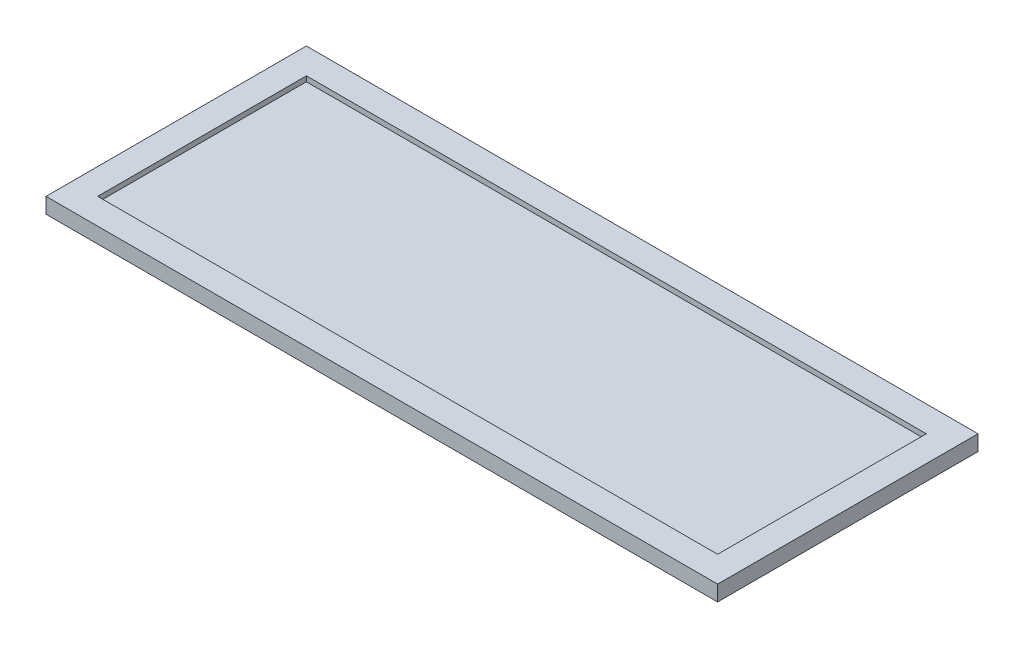
from build123d import *

# Parameters (mm, degrees)
SKETCH_1_W      = 650
SKETCH_1_H      = 252
SKETCH_1_W_2    = 600
SKETCH_1_H_2    = 202
EXTRUDE_1_DEPTH = 7.5
SKETCH_2_W      = 600
SKETCH_2_H      = 202
EXTRUDE_2_DEPTH = 2.5


with BuildPart() as part:
    # 草图1 → 凸台-拉伸1 (new body, symmetric)
    with BuildSketch(Plane(origin=(0, 0, 0), x_dir=(1, 0, 0), z_dir=(0, 1, 0))):
        Rectangle(SKETCH_1_W, SKETCH_1_H)
        Rectangle(SKETCH_1_W_2, SKETCH_1_H_2, mode=Mode.SUBTRACT)
    extrude(amount=EXTRUDE_1_DEPTH, both=True)

    # 草图2 → 凸台-拉伸2 (add, symmetric)
    with BuildSketch(Plane(origin=(0, 0, 0), x_dir=(1, 0, 0), z_dir=(0, 1, 0))):
        Rectangle(SKETCH_2_W, SKETCH_2_H)
    extrude(amount=EXTRUDE_2_DEPTH, both=True)


solid = part.part
